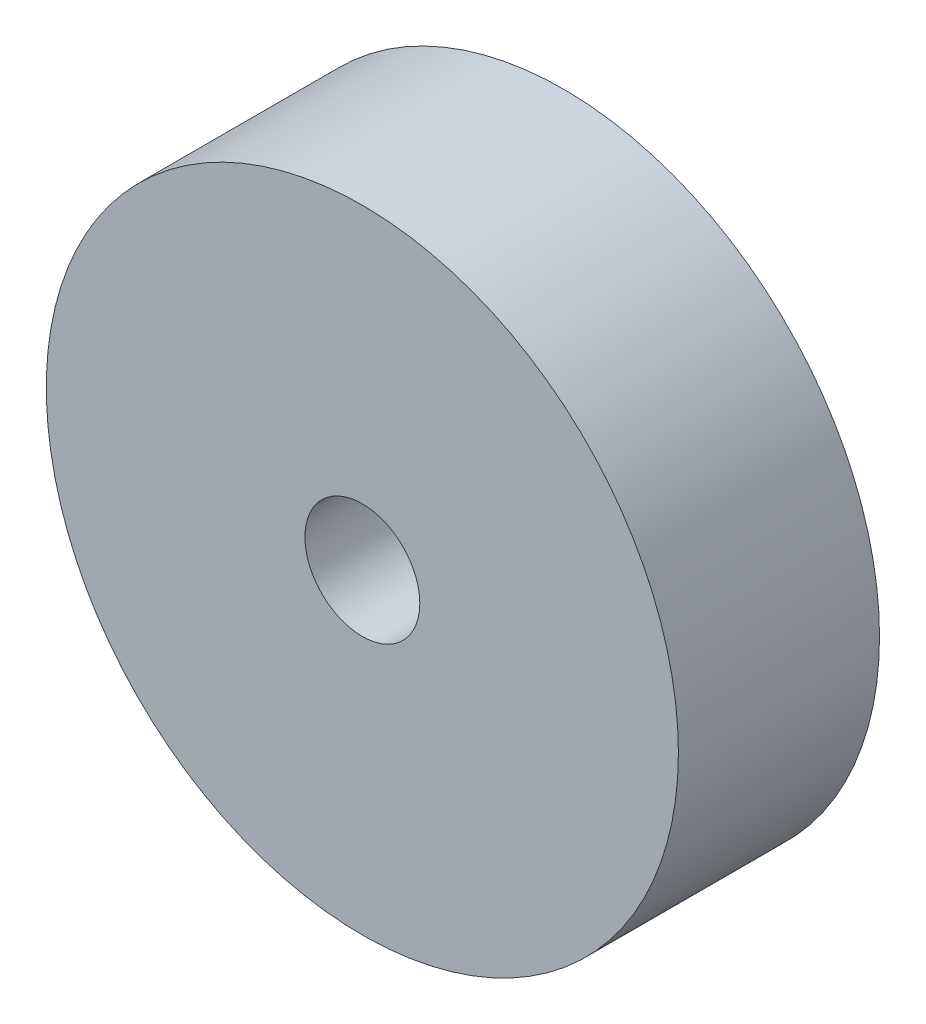
from build123d import *

# Parameters (mm, degrees)
SKETCH1_R           = 11
SKETCH1_R_2         = 2
BOSS_EXTRUDE1_DEPTH = 7


with BuildPart() as part:
    # Sketch1 → Boss-Extrude1 (new body)
    with BuildSketch(Plane.XY):
        Circle(SKETCH1_R)
        Circle(SKETCH1_R_2, mode=Mode.SUBTRACT)
    extrude(amount=BOSS_EXTRUDE1_DEPTH)


solid = part.part
